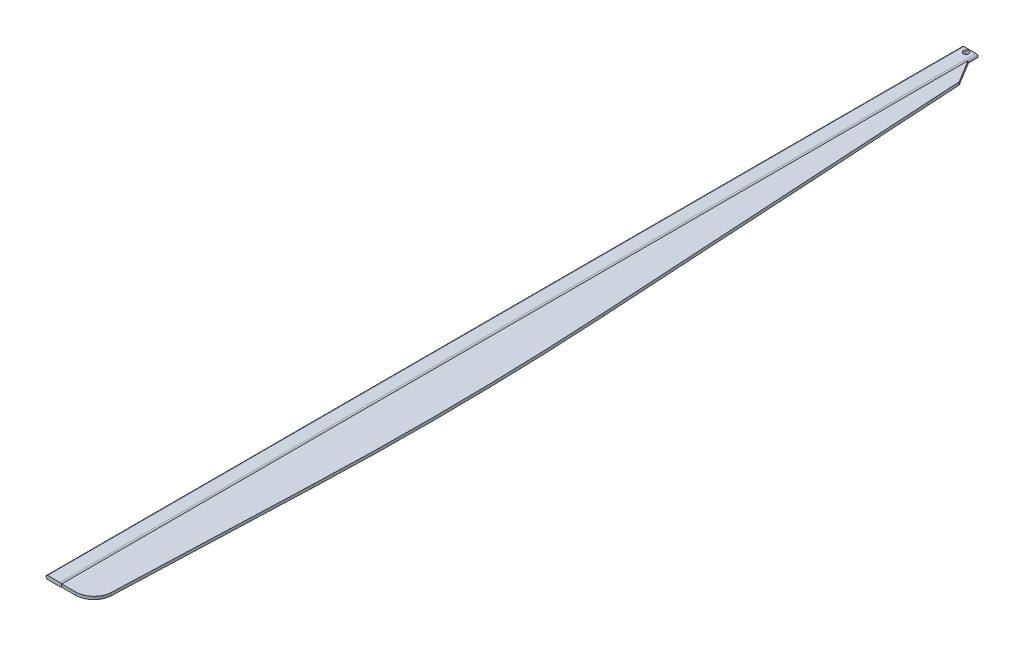
from build123d import *

# Parameters (mm, degrees)
SKETCH4_R                = 75
CUT_EXTRUDE1_DEPTH       = 101
FILLET1_R                = 20
BOSS_EXTRUDE1_DEPTH      = 40
BOSS_EXTRUDE1_DEPTH_BACK = 40


with BuildPart() as part:
    # Sweep1: sweep along a path in Sketch2
    with BuildLine(Plane(origin=(0, 0, 0), x_dir=(1, 0, 0), z_dir=(0, 1, 0))) as sweep1_path:
        Line((0, 0), (0, -25000))
    # Sketch1 → Sweep1 (sweep)
    with BuildSketch(Plane.XY):
        with BuildLine():
            Line((-165, 50), (165, 50))
            ThreePointArc((165, 50), (215, 0), (165, -50))
            Line((165, -50), (-165, -50))
            ThreePointArc((-165, -50), (-215, 0), (-165, 50))
        make_face()
    sweep(path=sweep1_path.line)

    # Sketch4 → Cut-Extrude1 (cut, through all)
    with BuildSketch(Plane(origin=(0, 50, 0), x_dir=(1, 0, 0), z_dir=(0, 1, 0))):
        with Locations((0, -120)):
            Circle(SKETCH4_R)
    extrude(amount=-CUT_EXTRUDE1_DEPTH, mode=Mode.SUBTRACT)

    # Fillet1
    fillet1_edges = [part.edges().sort_by_distance(p)[0] for p in [
        (-215, 0, 0),
        (0, -50, 0),
        (215, 0, 0),
        (0, 50, 0),
    ]]
    fillet(fillet1_edges, radius=FILLET1_R)


with BuildPart() as body_2:
    # Sketch3 → Boss-Extrude1 (new body, two sides)
    with BuildSketch(Plane(origin=(0, 0, 0), x_dir=(1, 0, 0), z_dir=(0, 1, 0))) as boss_extrude1_sk:
        with BuildLine():
            Line((215, -281.209140276), (591.052452888, -901.524429756))
            Line((591.052452888, -901.524429756), (1200.851543386, -11226.079055967))
            ThreePointArc((1200.851543386, -11226.079055967), (1340.354422594, -15214.36481836), (1288.088555363, -19204.747338236))
            Line((1288.088555363, -19204.747338236), (1090.707874725, -24518.559618227))
            ThreePointArc((1090.707874725, -24518.559618227), (937.98197807, -24860.05541873), (591.052452888, -25000))
            Line((591.052452888, -25000), (215, -25000))
            Line((215, -25000), (215, -281.209140276))
        make_face()
    extrude(amount=BOSS_EXTRUDE1_DEPTH)
    extrude(boss_extrude1_sk.sketch, amount=-BOSS_EXTRUDE1_DEPTH_BACK)


solid = Compound([part.part, body_2.part])
